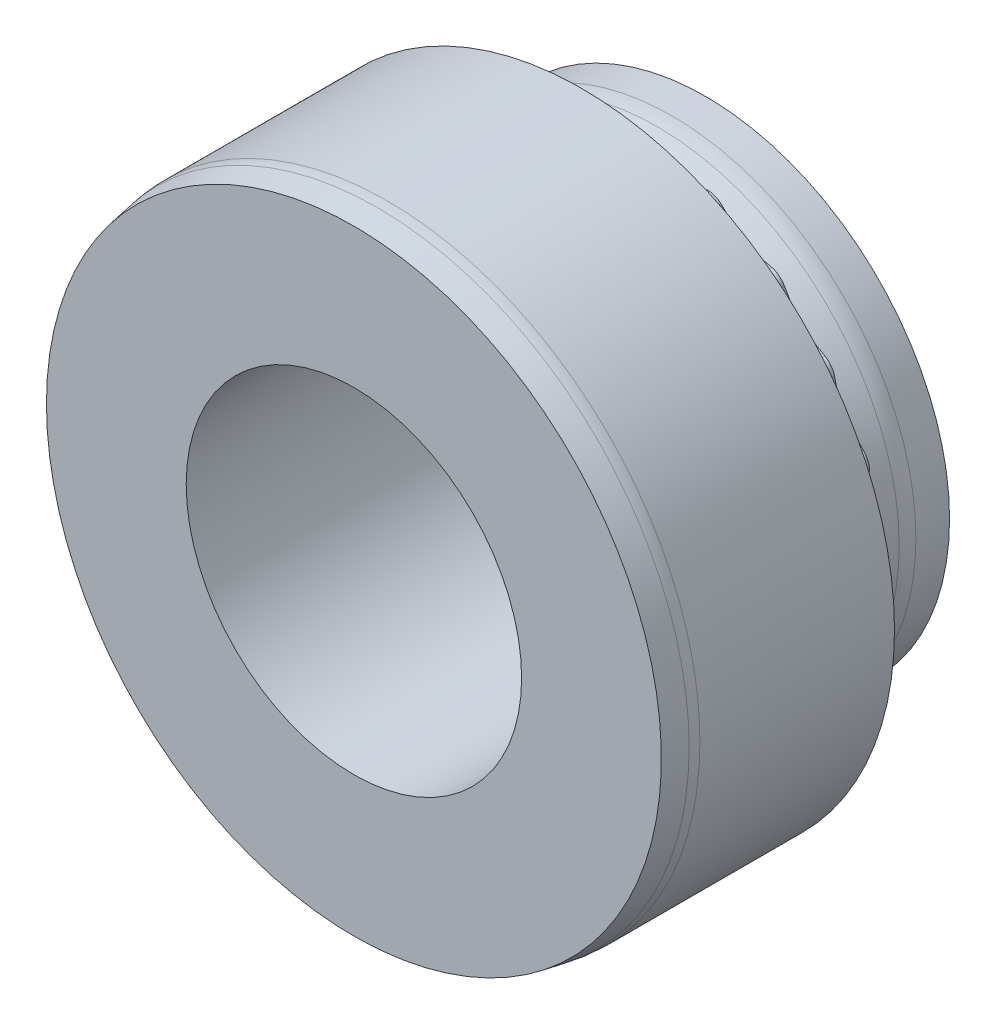
from build123d import *

# Parameters (mm, degrees)
CUT_EXTRUDE2_DEPTH       = 0.589333333
FILLET3_R                = 0.2194075
CIRPATTERN1_COUNT        = 24
FILLET3_OF_CIRPATTERN1_R = 0.2194075
FILLET4_R                = 0.2194075
SKETCH12_W               = 6.29
SKETCH12_H               = 3
CHAMFER1_SIZE            = 0.51
CHAMFER1_SIZE2           = 0.08992676
FILLET5_R                = 1.02


with BuildPart() as part:
    # Sketch2 → Revolve1 (revolve)
    with BuildSketch(Plane(origin=(0, 0, 0), x_dir=(0, 0, -1), z_dir=(1, 0, 0)), mode=Mode.PRIVATE) as revolve1_sk:
        Polygon((0, 0), (0, 4.365), (-0.736666667, 4.365), (-1.620666667, 4.128132914), (-1.620666667, 5.17075), (-2.21, 5.17075), (-2.21, 5.59), (-6.29, 5.59), (-6.29, 0), align=None)
    revolve(revolve1_sk.sketch.rotate(Axis((0, 0, 6.29), (0, 0, -1)), 90), axis=Axis((0, 0, 6.29), (0, 0, -1)))

    # Sketch5 → Cut-Extrude2 (cut)
    with BuildSketch(Plane(origin=(0, 0, 1.620666667), x_dir=(-1, 0, 0), z_dir=(0, 0, -1))):
        with BuildLine():
            Line((-5.119113982, -0.728922218), (-4.653675, 0))
            Line((-4.653675, 0), (-5.119113982, 0.728922218))
            ThreePointArc((-5.119113982, 0.728922218), (-5.17075, 0), (-5.119113982, -0.728922218))
        make_face()
    cut_extrude2 = extrude(amount=-CUT_EXTRUDE2_DEPTH, mode=Mode.SUBTRACT)

    # Fillet3
    fillet3_edges = [part.edges().sort_by_distance(p)[0] for p in [
        (4.653675, 0, 1.915333333),
    ]]
    fillet(fillet3_edges, radius=FILLET3_R)

    # CirPattern1: Cut-Extrude2 ×24 about axis
    cirpattern1_axis = Axis((0, 0, 0), (0, 0, 1))
    for i in range(1, CIRPATTERN1_COUNT):
        add(cut_extrude2.rotate(cirpattern1_axis, i * 360 / CIRPATTERN1_COUNT), mode=Mode.SUBTRACT)

    # Fillet3 of CirPattern1
    fillet3_of_cirpattern1_edges = [part.edges().sort_by_distance(p)[0] for p in [
        (4.49510487, 1.20445972, 1.915333333),
        (4.030200771, 2.3268375, 1.915333333),
        (3.29064515, 3.29064515, 1.915333333),
        (2.3268375, 4.030200771, 1.915333333),
        (1.20445972, 4.49510487, 1.915333333),
        (0, 4.653675, 1.915333333),
        (-1.20445972, 4.49510487, 1.915333333),
        (-2.3268375, 4.030200771, 1.915333333),
        (-3.29064515, 3.29064515, 1.915333333),
        (-4.030200771, 2.3268375, 1.915333333),
        (-4.49510487, 1.20445972, 1.915333333),
        (-4.653675, 0, 1.915333333),
        (-4.49510487, -1.20445972, 1.915333333),
        (-4.030200771, -2.3268375, 1.915333333),
        (-3.29064515, -3.29064515, 1.915333333),
        (-2.3268375, -4.030200771, 1.915333333),
        (-1.20445972, -4.49510487, 1.915333333),
        (0, -4.653675, 1.915333333),
        (1.20445972, -4.49510487, 1.915333333),
        (2.3268375, -4.030200771, 1.915333333),
        (3.29064515, -3.29064515, 1.915333333),
        (4.030200771, -2.3268375, 1.915333333),
        (4.49510487, -1.20445972, 1.915333333),
    ]]
    fillet(fillet3_of_cirpattern1_edges, radius=FILLET3_OF_CIRPATTERN1_R)

    # Fillet4
    fillet4_edges = [part.edges().sort_by_distance(p)[0] for p in [
        (5.080786875, 0.668898282, 1.915333333),
        (5.080786875, -0.668898282, 1.915333333),
        (4.734539646, 1.961110533, 1.915333333),
        (4.065641364, 3.119676342, 1.915333333),
        (3.119676342, 4.065641364, 1.915333333),
        (1.961110533, 4.734539646, 1.915333333),
        (0.668898282, 5.080786875, 1.915333333),
        (-0.668898282, 5.080786875, 1.915333333),
        (-1.961110533, 4.734539646, 1.915333333),
        (-3.119676342, 4.065641364, 1.915333333),
        (-4.065641364, 3.119676342, 1.915333333),
        (-4.734539646, 1.961110533, 1.915333333),
        (-5.080786875, 0.668898282, 1.915333333),
        (-5.080786875, -0.668898282, 1.915333333),
        (-4.734539646, -1.961110533, 1.915333333),
        (-4.065641364, -3.119676342, 1.915333333),
        (-3.119676342, -4.065641364, 1.915333333),
        (-1.961110533, -4.734539646, 1.915333333),
        (-0.668898282, -5.080786875, 1.915333333),
        (0.668898282, -5.080786875, 1.915333333),
        (1.961110533, -4.734539646, 1.915333333),
        (3.119676342, -4.065641364, 1.915333333),
        (4.065641364, -3.119676342, 1.915333333),
        (4.734539646, -1.961110533, 1.915333333),
    ]]
    fillet(fillet4_edges, radius=FILLET4_R)

    # Sketch11 → Cut-Revolve3 (revolve, cut)
    with BuildSketch(Plane(origin=(0, 0, 0), x_dir=(1, 0, 0), z_dir=(0, 1, 0))):
        Polygon((4.653675, -1.620666667), (5.17075, -1.808866576), (5.17075, -1.620666667), align=None)
    revolve(axis=Axis((0, 0, 6.29), (0, 0, -1)), mode=Mode.SUBTRACT)

    # Sketch12 → Cut-Revolve4 (revolve, cut)
    with BuildSketch(Plane(origin=(0, 0, 0), x_dir=(0, 0, -1), z_dir=(1, 0, 0)), mode=Mode.PRIVATE) as cut_revolve4_sk:
        with Locations((-3.145, -1.5)):
            Rectangle(SKETCH12_W, SKETCH12_H)
    revolve(cut_revolve4_sk.sketch.rotate(Axis((0, 0, 6.29), (0, 0, -1)), 270), axis=Axis((0, 0, 6.29), (0, 0, -1)), mode=Mode.SUBTRACT)

    # Chamfer1
    chamfer1_edges = [part.edges().sort_by_distance(p)[0] for p in [
        (-5.59, 0, 6.29),
    ]]
    chamfer1_side = [part.faces().sort_by_distance(p)[0] for p in [
        (-5.59, 0, 4.25),
    ]]
    chamfer(chamfer1_edges, length=CHAMFER1_SIZE, length2=CHAMFER1_SIZE2, reference=chamfer1_side[0])

    # Fillet5
    fillet5_edges = [part.edges().sort_by_distance(p)[0] for p in [
        (-5.59, 0, 5.78),
        (-4.365, 0, 0.736666667),
    ]]
    fillet(fillet5_edges, radius=FILLET5_R)


solid = part.part
